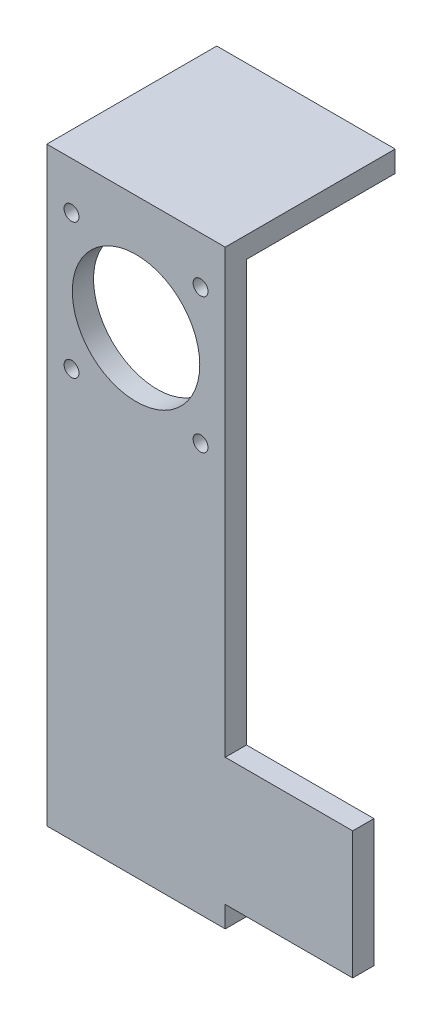
from build123d import *

# Parameters (mm, degrees)
SKETCH1_W                = 30
SKETCH1_H                = 30
SKETCH1_R                = 1.75
SKETCH1_R_2              = 15
BOSS_EXTRUDE1_DEPTH      = 5
SKETCH2_W                = 42
SKETCH2_H                = 5
BOSS_EXTRUDE3_DEPTH      = 35
BOSS_EXTRUDE3_DEPTH_BACK = 5


with BuildPart() as part:
    # Sketch1 → Boss-Extrude1 (new body)
    with BuildSketch(Plane.XY):
        with Locations((36, -92)):
            Rectangle(SKETCH1_W, SKETCH1_H)
        Polygon((-21, -22), (-21, -112), (21, -112), (21, -22), (21, 22), (-21, 22), align=None)
        with Locations((-15.190466427, 15.913821971)):
            Circle(SKETCH1_R, mode=Mode.SUBTRACT)
        with Locations((-15.190466427, -15.913821971)):
            Circle(SKETCH1_R, mode=Mode.SUBTRACT)
        with Locations((15.190466427, -15.913821971)):
            Circle(SKETCH1_R, mode=Mode.SUBTRACT)
        with Locations((15.190466427, 15.913821971)):
            Circle(SKETCH1_R, mode=Mode.SUBTRACT)
        Circle(SKETCH1_R_2, mode=Mode.SUBTRACT)
    extrude(amount=BOSS_EXTRUDE1_DEPTH)

    # Sketch2 → Boss-Extrude3 (add, two sides)
    with BuildSketch(Plane(origin=(0, 0, 0), x_dir=(-1, 0, 0), z_dir=(0, 0, -1))) as boss_extrude3_sk:
        with Locations((0, 24.5)):
            Rectangle(SKETCH2_W, SKETCH2_H)
    extrude(amount=BOSS_EXTRUDE3_DEPTH)
    extrude(boss_extrude3_sk.sketch, amount=-BOSS_EXTRUDE3_DEPTH_BACK)


solid = part.part
